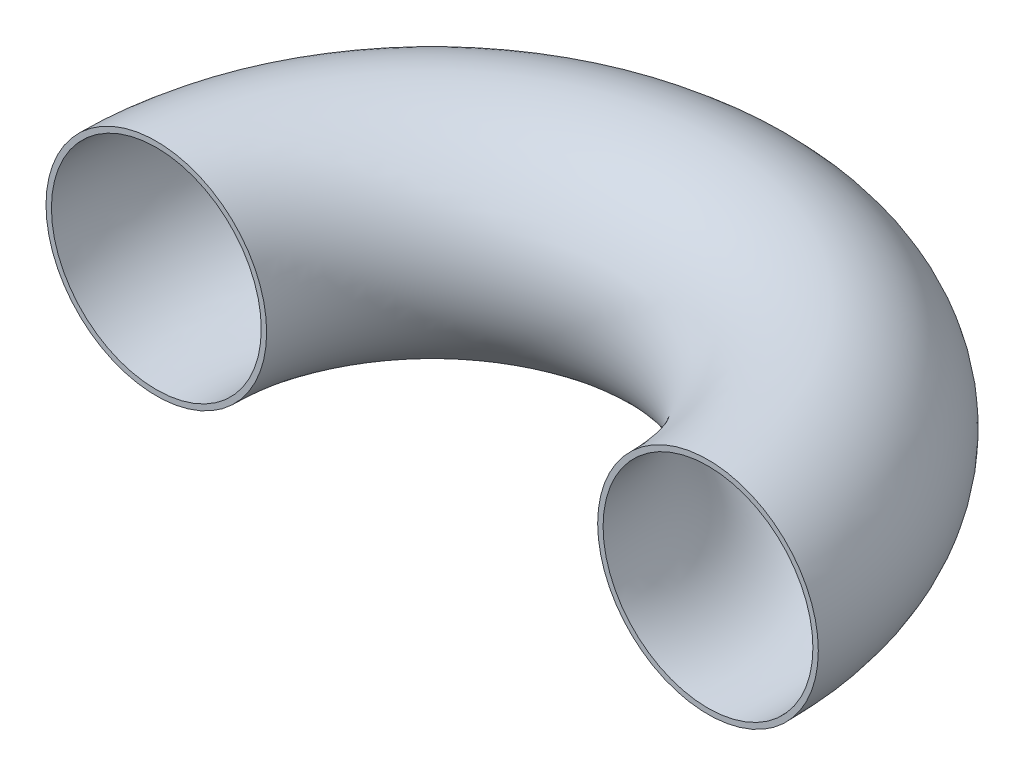
from build123d import *

# Parameters (mm, degrees)
SKETCH2_R   = 25.4
SKETCH2_R_2 = 24.1554


with BuildPart() as part:
    # Sweep1: sweep along a path in Sketch3
    with BuildLine(Plane(origin=(0, 0, 0), x_dir=(1, 0, 0), z_dir=(0, 1, 0))) as sweep1_path:
        ThreePointArc((0, 0), (63.5, 63.5), (127, 0))
    # Sketch2 → Sweep1 (sweep)
    with BuildSketch(Plane.XY):
        Circle(SKETCH2_R)
        Circle(SKETCH2_R_2, mode=Mode.SUBTRACT)
    sweep(path=sweep1_path.line)


solid = part.part
